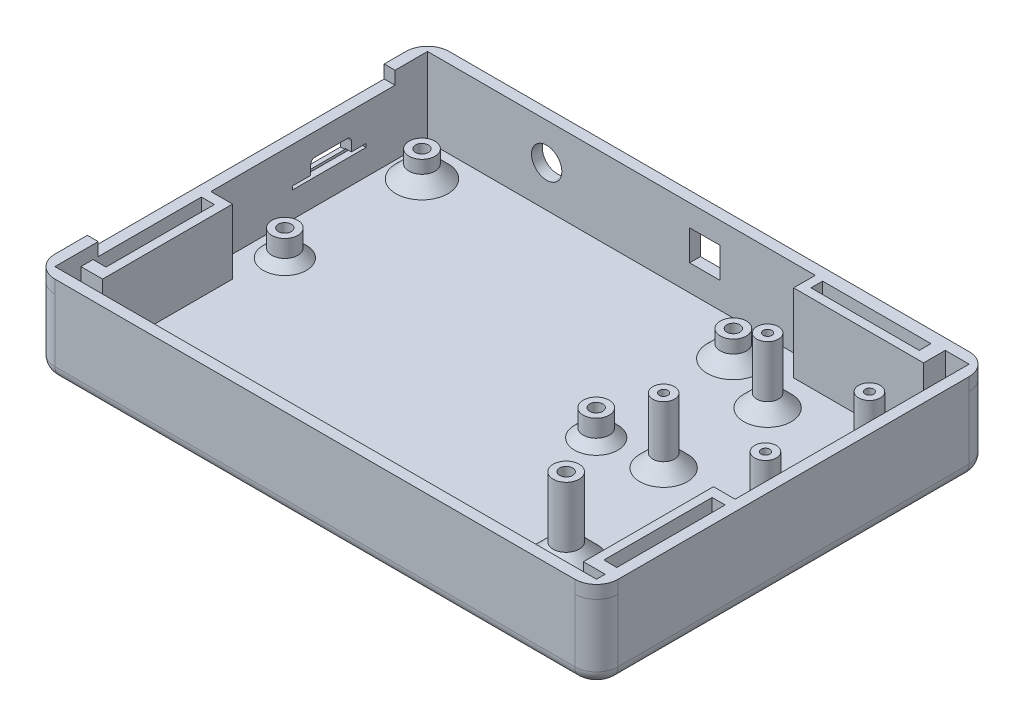
from build123d import *

# Parameters (mm, degrees)
SKETCH2_W            = 130
SKETCH2_H            = 91
BOSS_EXTRUDE1_DEPTH  = 2.5
SKETCH3_W            = 125
SKETCH3_H            = 2.5
BOSS_EXTRUDE2_DEPTH  = 15
SKETCH14_W           = 9.4
SKETCH14_H           = 3.4
CUT_EXTRUDE1_DEPTH   = 10
FILLET3_R            = 1
FILLET4_R            = 1
SKETCH17_W           = 17
SKETCH17_H           = 0.8
CUT_EXTRUDE3_DEPTH   = 1.5
SKETCH19_R           = 3
BOSS_EXTRUDE3_DEPTH  = 6
SKETCH20_R           = 1.5
CUT_EXTRUDE4_DEPTH   = 5
SKETCH21_R           = 3
BOSS_EXTRUDE4_DEPTH  = 6
SKETCH22_R           = 1.5
CUT_EXTRUDE5_DEPTH   = 5
SKETCH23_R           = 3
BOSS_EXTRUDE5_DEPTH  = 6
SKETCH24_R           = 1.5
CUT_EXTRUDE6_DEPTH   = 5
SKETCH25_R           = 3
BOSS_EXTRUDE6_DEPTH  = 6
SKETCH26_R           = 1.5
CUT_EXTRUDE7_DEPTH   = 5
FILLET5_R            = 5
SKETCH28_R           = 2.5
BOSS_EXTRUDE7_DEPTH  = 15
SKETCH29_R           = 2.5
BOSS_EXTRUDE8_DEPTH  = 15
SKETCH30_R           = 1
CUT_EXTRUDE8_DEPTH   = 6
SKETCH31_R           = 1
CUT_EXTRUDE9_DEPTH   = 6
SKETCH33_R           = 2.5
BOSS_EXTRUDE9_DEPTH  = 15
SKETCH34_R           = 2.5
BOSS_EXTRUDE10_DEPTH = 15
SKETCH35_R           = 1
CUT_EXTRUDE10_DEPTH  = 6
SKETCH36_R           = 1
CUT_EXTRUDE11_DEPTH  = 6
SKETCH39_W           = 130
SKETCH39_H           = 2.5
BOSS_EXTRUDE11_DEPTH = 3
SKETCH40_W           = 2.5
SKETCH40_H           = 91
BOSS_EXTRUDE12_DEPTH = 3
FILLET10_R           = 5
SKETCH41_W           = 130
SKETCH41_H           = 2.5
BOSS_EXTRUDE13_DEPTH = 3
FILLET11_R           = 5
SKETCH43_W           = 2.5
SKETCH43_H           = 10
BOSS_EXTRUDE14_DEPTH = 3
FILLET12_R           = 5
SKETCH45_W           = 2.5
SKETCH45_H           = 10
BOSS_EXTRUDE15_DEPTH = 3
FILLET13_R           = 5
SKETCH46_W           = 30
SKETCH46_H           = 5
BOSS_EXTRUDE16_DEPTH = 18
SKETCH47_W           = 5
SKETCH47_H           = 30
BOSS_EXTRUDE17_DEPTH = 18
SKETCH48_W           = 5
SKETCH48_H           = 30
BOSS_EXTRUDE18_DEPTH = 15
SKETCH49_W           = 25
SKETCH49_H           = 2.697812924
CUT_EXTRUDE12_DEPTH  = 10
SKETCH50_W           = 3
SKETCH50_H           = 25
CUT_EXTRUDE13_DEPTH  = 10
SKETCH51_W           = 3
SKETCH51_H           = 25
CUT_EXTRUDE14_DEPTH  = 10
SKETCH52_R           = 3
BOSS_EXTRUDE19_DEPTH = 18
SKETCH53_R           = 1.5
CUT_EXTRUDE15_DEPTH  = 16
FILLET14_R           = 3
CHAMFER2_SIZE        = 3
CHAMFER3_SIZE        = 2
CHAMFER4_SIZE        = 3
CHAMFER5_SIZE        = 3
CHAMFER6_SIZE        = 4
CHAMFER7_SIZE        = 2
SKETCH54_W           = 7
SKETCH54_H           = 7
CUT_EXTRUDE16_DEPTH  = 5
SKETCH55_R           = 3.5
CUT_EXTRUDE17_DEPTH  = 5


with BuildPart() as part:
    # Sketch2 → Boss-Extrude1 (new body)
    with BuildSketch(Plane(origin=(0, 0, 0), x_dir=(1, 0, 0), z_dir=(0, 1, 0))):
        with Locations((65, -45.5)):
            Rectangle(SKETCH2_W, SKETCH2_H)
    extrude(amount=BOSS_EXTRUDE1_DEPTH)

    # Sketch3 → Boss-Extrude2 (add)
    with BuildSketch(Plane(origin=(0, 2.5, 0), x_dir=(1, 0, 0), z_dir=(0, 1, 0))):
        Polygon((130, 0), (127.5, 0), (127.5, -2.5), (127.5, -88.5), (127.5, -91), (130, -91), align=None)
        with Locations((65, -1.25)):
            Rectangle(SKETCH3_W, SKETCH3_H)
        with Locations((65, -89.75)):
            Rectangle(SKETCH3_W, SKETCH3_H)
        Polygon((2.5, 0), (0, 0), (0, -91), (2.5, -91), (2.5, -88.5), (2.5, -2.5), align=None)
    extrude(amount=BOSS_EXTRUDE2_DEPTH)

    # Sketch14 → Cut-Extrude1 (cut)
    with BuildSketch(Plane(origin=(2.5, 0, 0), x_dir=(0, 0, -1), z_dir=(1, 0, 0))):
        with Locations((-24.78, 10.65)):
            Rectangle(SKETCH14_W, SKETCH14_H)
    extrude(amount=-CUT_EXTRUDE1_DEPTH, mode=Mode.SUBTRACT)

    # Fillet3
    fillet3_edges = [part.edges().sort_by_distance(p)[0] for p in [
        (1.25, 12.35, 20.08),
    ]]
    fillet(fillet3_edges, radius=FILLET3_R)

    # Fillet4
    fillet4_edges = [part.edges().sort_by_distance(p)[0] for p in [
        (1.25, 12.35, 29.48),
    ]]
    fillet(fillet4_edges, radius=FILLET4_R)

    # Sketch17 → Cut-Extrude3 (cut)
    with BuildSketch(Plane(origin=(2.5, 0, 0), x_dir=(0, 0, -1), z_dir=(1, 0, 0))):
        with Locations((-25.18, 8.8)):
            Rectangle(SKETCH17_W, SKETCH17_H)
    extrude(amount=-CUT_EXTRUDE3_DEPTH, mode=Mode.SUBTRACT)

    # Sketch19 → Boss-Extrude3 (add)
    with BuildSketch(Plane(origin=(0, 2.5, 0), x_dir=(1, 0, 0), z_dir=(0, 1, 0))):
        with Locations((9.3, -10.58)):
            Circle(SKETCH19_R)
    extrude(amount=BOSS_EXTRUDE3_DEPTH)

    # Sketch20 → Cut-Extrude4 (cut)
    with BuildSketch(Plane(origin=(0, 8.5, 0), x_dir=(1, 0, 0), z_dir=(0, 1, 0))):
        with Locations((9.3, -10.58)):
            Circle(SKETCH20_R)
    extrude(amount=-CUT_EXTRUDE4_DEPTH, mode=Mode.SUBTRACT)

    # Sketch21 → Boss-Extrude4 (add)
    with BuildSketch(Plane(origin=(0, 2.5, 0), x_dir=(1, 0, 0), z_dir=(0, 1, 0))):
        with Locations((9.3, -42.23)):
            Circle(SKETCH21_R)
    extrude(amount=BOSS_EXTRUDE4_DEPTH)

    # Sketch22 → Cut-Extrude5 (cut)
    with BuildSketch(Plane(origin=(0, 8.5, 0), x_dir=(1, 0, 0), z_dir=(0, 1, 0))):
        with Locations((9.3, -42.23)):
            Circle(SKETCH22_R)
    extrude(amount=-CUT_EXTRUDE5_DEPTH, mode=Mode.SUBTRACT)

    # Sketch23 → Boss-Extrude5 (add)
    with BuildSketch(Plane(origin=(0, 2.5, 0), x_dir=(1, 0, 0), z_dir=(0, 1, 0))):
        with Locations((81.17, -10.58)):
            Circle(SKETCH23_R)
    extrude(amount=BOSS_EXTRUDE5_DEPTH)

    # Sketch24 → Cut-Extrude6 (cut)
    with BuildSketch(Plane(origin=(0, 8.5, 0), x_dir=(1, 0, 0), z_dir=(0, 1, 0))):
        with Locations((81.17, -10.58)):
            Circle(SKETCH24_R)
    extrude(amount=-CUT_EXTRUDE6_DEPTH, mode=Mode.SUBTRACT)

    # Sketch25 → Boss-Extrude6 (add)
    with BuildSketch(Plane(origin=(0, 2.5, 0), x_dir=(1, 0, 0), z_dir=(0, 1, 0))):
        with Locations((81.17, -42.23)):
            Circle(SKETCH25_R)
    extrude(amount=BOSS_EXTRUDE6_DEPTH)

    # Sketch26 → Cut-Extrude7 (cut)
    with BuildSketch(Plane(origin=(0, 8.5, 0), x_dir=(1, 0, 0), z_dir=(0, 1, 0))):
        with Locations((81.17, -42.23)):
            Circle(SKETCH26_R)
    extrude(amount=-CUT_EXTRUDE7_DEPTH, mode=Mode.SUBTRACT)

    # Fillet5
    fillet5_edges = [part.edges().sort_by_distance(p)[0] for p in [
        (0, 8.75, 0),
        (130, 8.75, 0),
        (130, 8.75, 91),
        (0, 8.75, 91),
    ]]
    fillet(fillet5_edges, radius=FILLET5_R)

    # Sketch28 → Boss-Extrude7 (add)
    with BuildSketch(Plane(origin=(0, 2.5, 0), x_dir=(1, 0, 0), z_dir=(0, 1, 0))):
        with Locations((118.5, -16.5)):
            Circle(SKETCH28_R)
    extrude(amount=BOSS_EXTRUDE7_DEPTH)

    # Sketch29 → Boss-Extrude8 (add)
    with BuildSketch(Plane(origin=(0, 2.5, 0), x_dir=(1, 0, 0), z_dir=(0, 1, 0))):
        with Locations((118.5, -40.5)):
            Circle(SKETCH29_R)
    extrude(amount=BOSS_EXTRUDE8_DEPTH)

    # Sketch30 → Cut-Extrude8 (cut)
    with BuildSketch(Plane(origin=(0, 17.5, 0), x_dir=(1, 0, 0), z_dir=(0, 1, 0))):
        with Locations((118.5, -16.5)):
            Circle(SKETCH30_R)
    extrude(amount=-CUT_EXTRUDE8_DEPTH, mode=Mode.SUBTRACT)

    # Sketch31 → Cut-Extrude9 (cut)
    with BuildSketch(Plane(origin=(0, 17.5, 0), x_dir=(1, 0, 0), z_dir=(0, 1, 0))):
        with Locations((118.5, -40.5)):
            Circle(SKETCH31_R)
    extrude(amount=-CUT_EXTRUDE9_DEPTH, mode=Mode.SUBTRACT)

    # Sketch33 → Boss-Extrude9 (add)
    with BuildSketch(Plane(origin=(0, 2.5, 0), x_dir=(1, 0, 0), z_dir=(0, 1, 0))):
        with Locations((95, -16.5)):
            Circle(SKETCH33_R)
    extrude(amount=BOSS_EXTRUDE9_DEPTH)

    # Sketch34 → Boss-Extrude10 (add)
    with BuildSketch(Plane(origin=(0, 2.5, 0), x_dir=(1, 0, 0), z_dir=(0, 1, 0))):
        with Locations((95, -40.5)):
            Circle(SKETCH34_R)
    extrude(amount=BOSS_EXTRUDE10_DEPTH)

    # Sketch35 → Cut-Extrude10 (cut)
    with BuildSketch(Plane(origin=(0, 17.5, 0), x_dir=(1, 0, 0), z_dir=(0, 1, 0))):
        with Locations((95, -16.5)):
            Circle(SKETCH35_R)
    extrude(amount=-CUT_EXTRUDE10_DEPTH, mode=Mode.SUBTRACT)

    # Sketch36 → Cut-Extrude11 (cut)
    with BuildSketch(Plane(origin=(0, 17.5, 0), x_dir=(1, 0, 0), z_dir=(0, 1, 0))):
        with Locations((95, -40.5)):
            Circle(SKETCH36_R)
    extrude(amount=-CUT_EXTRUDE11_DEPTH, mode=Mode.SUBTRACT)

    # Sketch39 → Boss-Extrude11 (add)
    with BuildSketch(Plane(origin=(0, 17.5, 0), x_dir=(1, 0, 0), z_dir=(0, 1, 0))):
        with Locations((65, -89.75)):
            Rectangle(SKETCH39_W, SKETCH39_H)
    extrude(amount=BOSS_EXTRUDE11_DEPTH)

    # Sketch40 → Boss-Extrude12 (add)
    with BuildSketch(Plane(origin=(0, 17.5, 0), x_dir=(1, 0, 0), z_dir=(0, 1, 0))):
        with Locations((128.75, -45.5)):
            Rectangle(SKETCH40_W, SKETCH40_H)
    extrude(amount=BOSS_EXTRUDE12_DEPTH)

    # Fillet10
    fillet10_edges = [part.edges().sort_by_distance(p)[0] for p in [
        (130, 19, 91),
    ]]
    fillet(fillet10_edges, radius=FILLET10_R)

    # Sketch41 → Boss-Extrude13 (add)
    with BuildSketch(Plane(origin=(0, 17.5, 0), x_dir=(1, 0, 0), z_dir=(0, 1, 0))):
        with Locations((65, -1.25)):
            Rectangle(SKETCH41_W, SKETCH41_H)
    extrude(amount=BOSS_EXTRUDE13_DEPTH)

    # Fillet11
    fillet11_edges = [part.edges().sort_by_distance(p)[0] for p in [
        (130, 19, 0),
    ]]
    fillet(fillet11_edges, radius=FILLET11_R)

    # Sketch43 → Boss-Extrude14 (add)
    with BuildSketch(Plane(origin=(0, 17.5, 0), x_dir=(1, 0, 0), z_dir=(0, 1, 0))):
        with Locations((1.25, -5)):
            Rectangle(SKETCH43_W, SKETCH43_H)
    extrude(amount=BOSS_EXTRUDE14_DEPTH)

    # Fillet12
    fillet12_edges = [part.edges().sort_by_distance(p)[0] for p in [
        (0, 19, 0),
    ]]
    fillet(fillet12_edges, radius=FILLET12_R)

    # Sketch45 → Boss-Extrude15 (add)
    with BuildSketch(Plane(origin=(0, 17.5, 0), x_dir=(1, 0, 0), z_dir=(0, 1, 0))):
        with Locations((1.25, -83.5)):
            Rectangle(SKETCH45_W, SKETCH45_H)
    extrude(amount=BOSS_EXTRUDE15_DEPTH)

    # Fillet13
    fillet13_edges = [part.edges().sort_by_distance(p)[0] for p in [
        (0, 19, 91),
    ]]
    fillet(fillet13_edges, radius=FILLET13_R)

    # Sketch46 → Boss-Extrude16 (add)
    with BuildSketch(Plane(origin=(0, 2.5, 0), x_dir=(1, 0, 0), z_dir=(0, 1, 0))):
        with Locations((107, -5)):
            Rectangle(SKETCH46_W, SKETCH46_H)
    extrude(amount=BOSS_EXTRUDE16_DEPTH)

    # Sketch47 → Boss-Extrude17 (add)
    with BuildSketch(Plane(origin=(0, 2.5, 0), x_dir=(1, 0, 0), z_dir=(0, 1, 0))):
        with Locations((125, -71.5)):
            Rectangle(SKETCH47_W, SKETCH47_H)
    extrude(amount=BOSS_EXTRUDE17_DEPTH)

    # Sketch48 → Boss-Extrude18 (add)
    with BuildSketch(Plane(origin=(0, 2.5, 0), x_dir=(1, 0, 0), z_dir=(0, 1, 0))):
        with Locations((5, -67.5)):
            Rectangle(SKETCH48_W, SKETCH48_H)
    extrude(amount=BOSS_EXTRUDE18_DEPTH)

    # Sketch49 → Cut-Extrude12 (cut)
    with BuildSketch(Plane(origin=(0, 20.5, 0), x_dir=(1, 0, 0), z_dir=(0, 1, 0))):
        with Locations((106.5, -4.151093538)):
            Rectangle(SKETCH49_W, SKETCH49_H)
    extrude(amount=-CUT_EXTRUDE12_DEPTH, mode=Mode.SUBTRACT)

    # Sketch50 → Cut-Extrude13 (cut)
    with BuildSketch(Plane(origin=(0, 17.5, 0), x_dir=(1, 0, 0), z_dir=(0, 1, 0))):
        with Locations((4, -67.2)):
            Rectangle(SKETCH50_W, SKETCH50_H)
    extrude(amount=-CUT_EXTRUDE13_DEPTH, mode=Mode.SUBTRACT)

    # Sketch51 → Cut-Extrude14 (cut)
    with BuildSketch(Plane(origin=(0, 20.5, 0), x_dir=(1, 0, 0), z_dir=(0, 1, 0))):
        with Locations((126, -71.3)):
            Rectangle(SKETCH51_W, SKETCH51_H)
    extrude(amount=-CUT_EXTRUDE14_DEPTH, mode=Mode.SUBTRACT)

    # Sketch52 → Boss-Extrude19 (add)
    with BuildSketch(Plane(origin=(0, 2.5, 0), x_dir=(1, 0, 0), z_dir=(0, 1, 0))):
        with Locations((102.5, -70.5)):
            Circle(SKETCH52_R)
    extrude(amount=BOSS_EXTRUDE19_DEPTH)

    # Sketch53 → Cut-Extrude15 (cut)
    with BuildSketch(Plane(origin=(0, 20.5, 0), x_dir=(1, 0, 0), z_dir=(0, 1, 0))):
        with Locations((102.5, -70.5)):
            Circle(SKETCH53_R)
    extrude(amount=-CUT_EXTRUDE15_DEPTH, mode=Mode.SUBTRACT)

    # Fillet14
    fillet14_edges = [part.edges().sort_by_distance(p)[0] for p in [
        (0, 0, 45.5),
        (65, 0, 0),
        (130, 0, 45.5),
        (65, 0, 91),
        (1.464466094, 0, 89.535533906),
        (128.535533906, 0, 89.535533906),
        (128.535533906, 0, 1.464466094),
        (1.464466094, 0, 1.464466094),
    ]]
    fillet(fillet14_edges, radius=FILLET14_R)

    # Chamfer2
    chamfer2_edges = [part.edges().sort_by_distance(p)[0] for p in [
        (6.3, 2.5, 10.58),
    ]]
    chamfer(chamfer2_edges, length=CHAMFER2_SIZE)

    # Chamfer3
    chamfer3_edges = [part.edges().sort_by_distance(p)[0] for p in [
        (6.3, 2.5, 42.23),
    ]]
    chamfer(chamfer3_edges, length=CHAMFER3_SIZE)

    # Chamfer4
    chamfer4_edges = [part.edges().sort_by_distance(p)[0] for p in [
        (78.17, 2.5, 10.58),
    ]]
    chamfer(chamfer4_edges, length=CHAMFER4_SIZE)

    # Chamfer5
    chamfer5_edges = [part.edges().sort_by_distance(p)[0] for p in [
        (116, 2.5, 16.5),
        (116, 2.5, 40.5),
        (92.5, 2.5, 16.5),
        (92.5, 2.5, 40.5),
    ]]
    chamfer(chamfer5_edges, length=CHAMFER5_SIZE)

    # Chamfer6
    chamfer6_edges = [part.edges().sort_by_distance(p)[0] for p in [
        (99.5, 2.5, 70.5),
    ]]
    chamfer(chamfer6_edges, length=CHAMFER6_SIZE)

    # Chamfer7
    chamfer7_edges = [part.edges().sort_by_distance(p)[0] for p in [
        (78.17, 2.5, 42.23),
    ]]
    chamfer(chamfer7_edges, length=CHAMFER7_SIZE)

    # Sketch54 → Cut-Extrude16 (cut, symmetric)
    with BuildSketch(Plane(origin=(0, 0, 0), x_dir=(-1, 0, 0), z_dir=(0, 0, -1))):
        with Locations((-66.5, 12)):
            Rectangle(SKETCH54_W, SKETCH54_H)
    extrude(amount=CUT_EXTRUDE16_DEPTH, both=True, mode=Mode.SUBTRACT)

    # Sketch55 → Cut-Extrude17 (cut, symmetric)
    with BuildSketch(Plane(origin=(0, 0, 0), x_dir=(-1, 0, 0), z_dir=(0, 0, -1))):
        with Locations((-30, 12)):
            Circle(SKETCH55_R)
    extrude(amount=CUT_EXTRUDE17_DEPTH, both=True, mode=Mode.SUBTRACT)


solid = part.part
